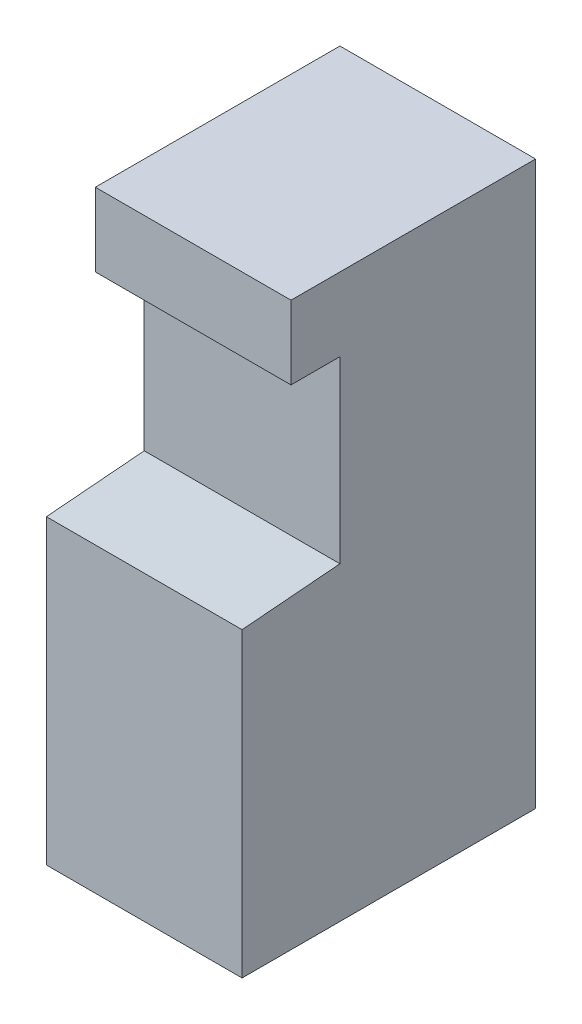
from build123d import *

# Parameters (mm, degrees)
SKETCH1_W           = 609.6
SKETCH1_H           = 914.4
BOSS_EXTRUDE1_DEPTH = 939.8
SKETCH2_W           = 609.6
SKETCH2_H           = 304.8
BOSS_EXTRUDE2_DEPTH = 25.4
CUT_EXTRUDE1_DEPTH  = 610.6
SKETCH4_W           = 609.6
SKETCH4_H           = 609.6
BOSS_EXTRUDE3_DEPTH = 25.4
SKETCH5_W           = 609.6
SKETCH5_H           = 609.6
BOSS_EXTRUDE4_DEPTH = 558.8
SKETCH6_W           = 609.6
SKETCH6_H           = 609.6
BOSS_EXTRUDE5_DEPTH = 228.6
SKETCH7_W           = 609.6
SKETCH7_H           = 228.6
BOSS_EXTRUDE6_DEPTH = 152.4


with BuildPart() as part:
    # Sketch1 → Boss-Extrude1 (new body)
    with BuildSketch(Plane(origin=(0, 0, 0), x_dir=(1, 0, 0), z_dir=(0, 1, 0))):
        with Locations((304.8, -457.2)):
            Rectangle(SKETCH1_W, SKETCH1_H)
    extrude(amount=BOSS_EXTRUDE1_DEPTH)

    # Sketch2 → Boss-Extrude2 (add)
    with BuildSketch(Plane(origin=(0, 939.8, 0), x_dir=(1, 0, 0), z_dir=(0, 1, 0))):
        with Locations((304.8, -762)):
            Rectangle(SKETCH2_W, SKETCH2_H)
    extrude(amount=BOSS_EXTRUDE2_DEPTH)

    # Sketch3 → Cut-Extrude1 (cut, through all)
    with BuildSketch(Plane.ZY):
        Polygon((609.6, 965.2), (914.4, 939.8), (914.4, 965.2), align=None)
    extrude(amount=-CUT_EXTRUDE1_DEPTH, mode=Mode.SUBTRACT)

    # Sketch4 → Boss-Extrude3 (add)
    with BuildSketch(Plane(origin=(0, 939.8, 0), x_dir=(1, 0, 0), z_dir=(0, 1, 0))):
        with Locations((304.8, -304.8)):
            Rectangle(SKETCH4_W, SKETCH4_H)
    extrude(amount=BOSS_EXTRUDE3_DEPTH)

    # Sketch5 → Boss-Extrude4 (add)
    with BuildSketch(Plane(origin=(0, 965.2, 0), x_dir=(1, 0, 0), z_dir=(0, 1, 0))):
        with Locations((304.8, -304.8)):
            Rectangle(SKETCH5_W, SKETCH5_H)
    extrude(amount=BOSS_EXTRUDE4_DEPTH)

    # Sketch6 → Boss-Extrude5 (add)
    with BuildSketch(Plane(origin=(0, 1524, 0), x_dir=(1, 0, 0), z_dir=(0, 1, 0))):
        with Locations((304.8, -304.8)):
            Rectangle(SKETCH6_W, SKETCH6_H)
    extrude(amount=BOSS_EXTRUDE5_DEPTH)

    # Sketch7 → Boss-Extrude6 (add)
    with BuildSketch(Plane.XY.offset(609.6)):
        with Locations((304.8, 1638.3)):
            Rectangle(SKETCH7_W, SKETCH7_H)
    extrude(amount=BOSS_EXTRUDE6_DEPTH)


solid = part.part
